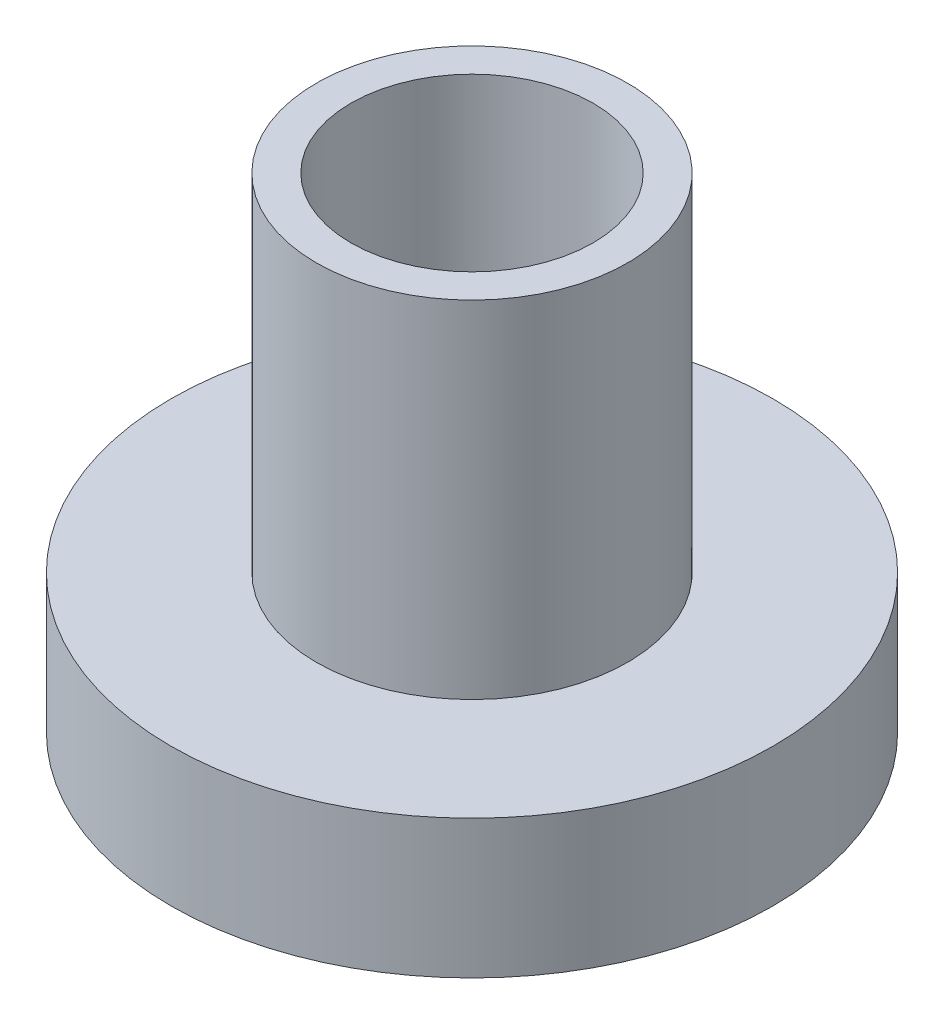
from build123d import *

# Parameters (mm, degrees)
SKETCH1_R           = 4.35
BOSS_EXTRUDE1_DEPTH = 2
SKETCH2_R           = 2.25
BOSS_EXTRUDE2_DEPTH = 5
SKETCH3_R           = 1.75
CUT_EXTRUDE1_DEPTH  = 8


with BuildPart() as part:
    # Sketch1 → Boss-Extrude1 (new body)
    with BuildSketch(Plane(origin=(0, 0, 0), x_dir=(1, 0, 0), z_dir=(0, 1, 0))):
        Circle(SKETCH1_R)
    extrude(amount=BOSS_EXTRUDE1_DEPTH)

    # Sketch2 → Boss-Extrude2 (add)
    with BuildSketch(Plane(origin=(0, 2, 0), x_dir=(1, 0, 0), z_dir=(0, 1, 0))):
        Circle(SKETCH2_R)
    extrude(amount=BOSS_EXTRUDE2_DEPTH)

    # Sketch3 → Cut-Extrude1 (cut, through all)
    with BuildSketch(Plane(origin=(0, 7, 0), x_dir=(1, 0, 0), z_dir=(0, 1, 0))):
        Circle(SKETCH3_R)
    extrude(amount=-CUT_EXTRUDE1_DEPTH, mode=Mode.SUBTRACT)


solid = part.part
